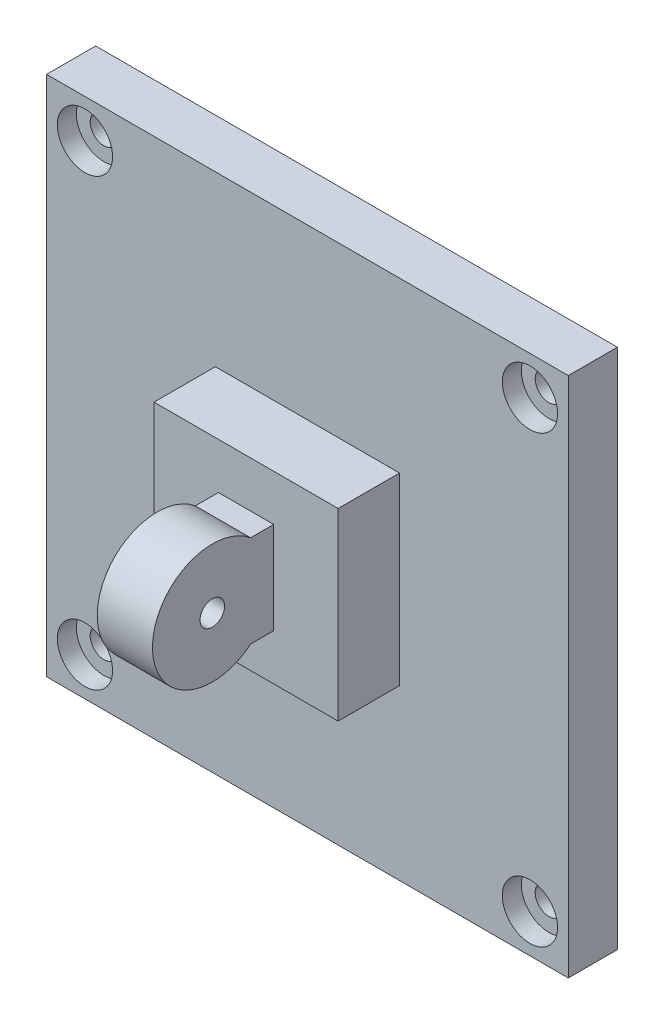
from build123d import *

# Parameters (mm, degrees)
ESBO_O1_W                                            = 85
ESBO_O1_H                                            = 85
RESSALTO_EXTRUS_O1_DEPTH                             = 8
REBAIXO_PARA_PARAFUSO_DE_M_QUINA_COM_CAB_D           = 4.5
REBAIXO_PARA_PARAFUSO_DE_M_QUINA_COM_CAB_CBORE_D     = 9
REBAIXO_PARA_PARAFUSO_DE_M_QUINA_COM_CAB_CBORE_DEPTH = 3.1
ESBO_O5_W                                            = 30
ESBO_O5_H                                            = 30
RESSALTO_EXTRUS_O2_DEPTH                             = 20
ESBO_O6_R                                            = 10
CORTE_EXTRUS_O1_DEPTH                                = 10
ESBO_O7_R                                            = 10
CORTE_EXTRUS_O2_DEPTH                                = 10
CORTE_EXTRUS_O3_DEPTH                                = 58.5
ESBO_O9_W                                            = 9
ESBO_O9_H                                            = 15
RESSALTO_EXTRUS_O3_DEPTH                             = 10
ESBO_O10_R                                           = 9.75
RESSALTO_EXTRUS_O4_DEPTH                             = 9
ESBO_O11_R                                           = 2
CORTE_EXTRUS_O4_DEPTH                                = 48


with BuildPart() as part:
    # Esboço1 → Ressalto-extrusão1 (new body)
    with BuildSketch(Plane.XY):
        Rectangle(ESBO_O1_W, ESBO_O1_H)
    extrude(amount=RESSALTO_EXTRUS_O1_DEPTH)

    # Rebaixo para parafuso de máquina com cabeça panela de M41 (through all)
    with Locations(Plane.XY.offset(8)):
        with Locations((-36.25, 36.25), (-36.25, -36.25), (36.25, -36.25), (36.25, 36.25)):
            CounterBoreHole(REBAIXO_PARA_PARAFUSO_DE_M_QUINA_COM_CAB_D / 2, REBAIXO_PARA_PARAFUSO_DE_M_QUINA_COM_CAB_CBORE_D / 2, REBAIXO_PARA_PARAFUSO_DE_M_QUINA_COM_CAB_CBORE_DEPTH)

    # Esboço5 → Ressalto-extrusão2 (add)
    with BuildSketch(Plane.XY.offset(8)):
        Rectangle(ESBO_O5_W, ESBO_O5_H)
    extrude(amount=RESSALTO_EXTRUS_O2_DEPTH)

    # Esboço6 → Corte-extrusão1 (cut)
    with BuildSketch(Plane(origin=(15, 0, 0), x_dir=(0, 0, -1), z_dir=(1, 0, 0))):
        with Locations((-28, 0)):
            Circle(ESBO_O6_R)
    extrude(amount=-CORTE_EXTRUS_O1_DEPTH, mode=Mode.SUBTRACT)

    # Esboço7 → Corte-extrusão2 (cut)
    with BuildSketch(Plane.ZY.offset(15)):
        with Locations((28, 0)):
            Circle(ESBO_O7_R)
    extrude(amount=-CORTE_EXTRUS_O2_DEPTH, mode=Mode.SUBTRACT)

    # Esboço8 → Corte-extrusão3 (cut, through all)
    with BuildSketch(Plane.ZY.offset(15)):
        Polygon((18, 10), (18, 15), (28, 15), (28, 10), (28, -10), (28, -15), (18, -15), (18, -10), align=None)
    extrude(amount=-CORTE_EXTRUS_O3_DEPTH, mode=Mode.SUBTRACT)

    # Esboço9 → Ressalto-extrusão3 (add)
    with BuildSketch(Plane.XY.offset(18)):
        Rectangle(ESBO_O9_W, ESBO_O9_H)
    extrude(amount=RESSALTO_EXTRUS_O3_DEPTH)

    # Esboço10 → Ressalto-extrusão4 (add)
    with BuildSketch(Plane.ZY.offset(4.5)):
        with Locations((28, 0)):
            Circle(ESBO_O10_R)
    extrude(amount=-RESSALTO_EXTRUS_O4_DEPTH)

    # Esboço11 → Corte-extrusão4 (cut, through all)
    with BuildSketch(Plane.ZY.offset(4.5)):
        with Locations((28, 0)):
            Circle(ESBO_O11_R)
    extrude(amount=-CORTE_EXTRUS_O4_DEPTH, mode=Mode.SUBTRACT)


solid = part.part
